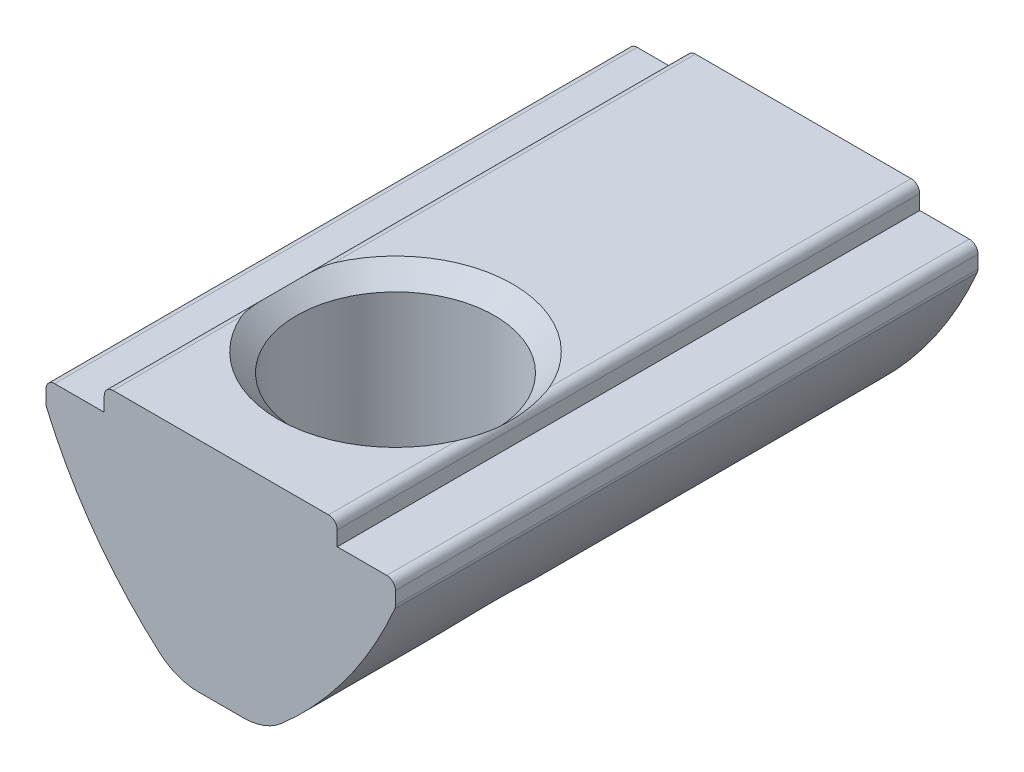
from build123d import *

# Parameters (mm, degrees)
EXTRUDE_1_DEPTH             = 10
FILLET_1_R                  = 0.3
FILLET_2_R                  = 2
HOLE_WIZARD_M81_D           = 6.8
HOLE_WIZARD_M81_CSINK_D     = 8.05
HOLE_WIZARD_M81_CSINK_ANGLE = 90


with BuildPart() as part:
    # Эскиз1 → Бобышка-Вытянуть1 (new body, symmetric)
    with BuildSketch(Plane.XY):
        with BuildLine():
            Line((-4, 0), (4, 0))
            Line((4, 0), (4, -0.8))
            Line((4, -0.8), (6, -0.8))
            Line((6, -0.8), (6, -1.6))
            ThreePointArc((6, -1.6), (4.120585945, -4.832650297), (1.5, -7.5))
            Line((1.5, -7.5), (-1.5, -7.5))
            ThreePointArc((-1.5, -7.5), (-4.120585945, -4.832650297), (-6, -1.6))
            Line((-6, -1.6), (-6, -0.8))
            Line((-6, -0.8), (-4, -0.8))
            Line((-4, -0.8), (-4, 0))
        make_face()
    extrude(amount=EXTRUDE_1_DEPTH, both=True)

    # Скругление1
    fillet_1_edges = [part.edges().sort_by_distance(p)[0] for p in [
        (6, -0.8, 0),
        (6, -1.6, 0),
        (-6, -1.6, 0),
        (-6, -0.8, 0),
        (-4, 0, 0),
        (4, 0, 0),
    ]]
    fillet(fillet_1_edges, radius=FILLET_1_R)

    # Скругление2
    fillet_2_edges = [part.edges().sort_by_distance(p)[0] for p in [
        (1.5, -7.5, 0),
        (-1.5, -7.5, 0),
    ]]
    fillet(fillet_2_edges, radius=FILLET_2_R)

    # Отверстие обработанное метчиком M81 (through all)
    with Locations(Plane(origin=(0, 0, 0), x_dir=(1, 0, 0), z_dir=(0, 1, 0))):
        with Locations((0, -4)):
            CounterSinkHole(HOLE_WIZARD_M81_D / 2, HOLE_WIZARD_M81_CSINK_D / 2, counter_sink_angle=HOLE_WIZARD_M81_CSINK_ANGLE)

    # Эскиз5 → Повернуть1 (revolve)
    with BuildSketch(Plane(origin=(0, 0, 0), x_dir=(0, 0, -1), z_dir=(1, 0, 0))):
        with BuildLine():
            Line((6, -4.3), (6, -8.3))
            ThreePointArc((6, -8.3), (4, -6.3), (6, -4.3))
        make_face()
    revolve(axis=Axis((0, -4.3, -6), (0, -1, 0)))


solid = part.part
